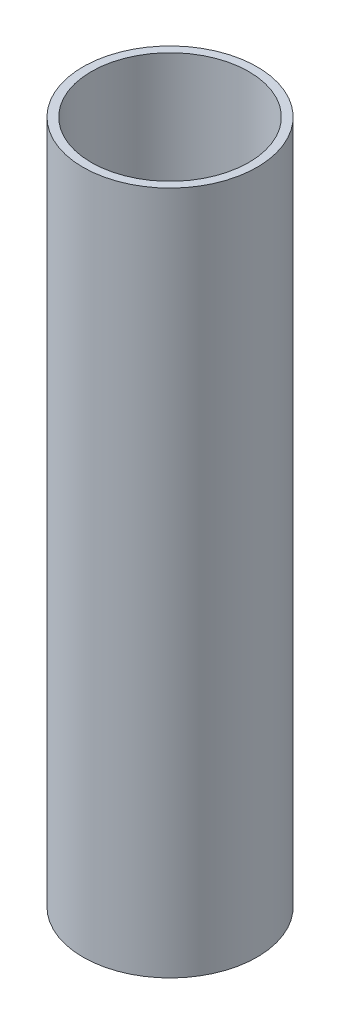
from build123d import *

# Parameters (mm, degrees)
SKETCH1_R           = 21
SKETCH1_R_2         = 19
BOSS_EXTRUDE1_DEPTH = 165


with BuildPart() as part:
    # Sketch1 → Boss-Extrude1 (new body)
    with BuildSketch(Plane(origin=(0, 0, 0), x_dir=(1, 0, 0), z_dir=(0, 1, 0))):
        Circle(SKETCH1_R)
        Circle(SKETCH1_R_2, mode=Mode.SUBTRACT)
    extrude(amount=BOSS_EXTRUDE1_DEPTH)


solid = part.part
